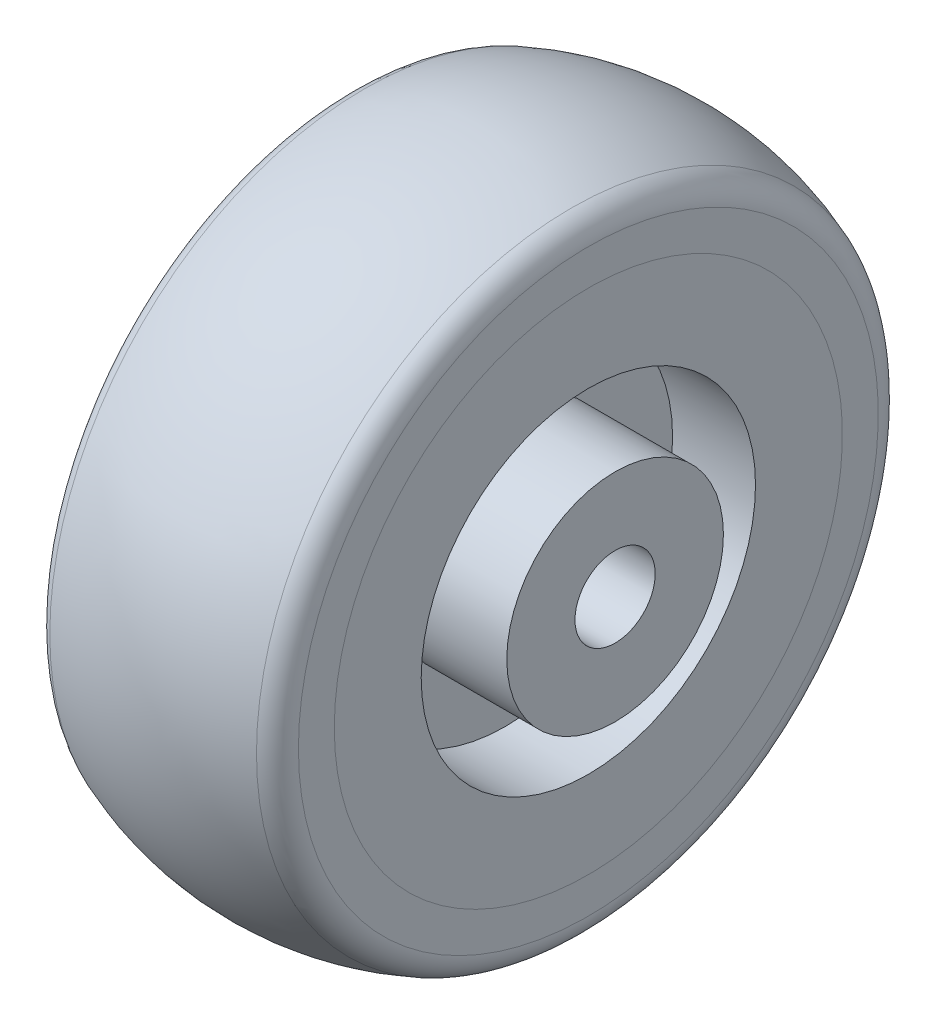
from build123d import *


with BuildPart() as part:
    # Esquisse2 → Révolution1 (revolve)
    with BuildSketch(Plane.XY):
        with BuildLine():
            Line((-11, 3), (11, 3))
            Line((11, 3), (11, 8.1))
            Line((11, 8.1), (2.8, 8.1))
            Line((2.8, 8.1), (2.8, 12.5))
            Line((2.8, 12.5), (9, 12.5))
            Line((9, 12.5), (9, 21.68216384))
            ThreePointArc((9, 21.68216384), (8.651445648, 22.81031599), (7.727272727, 23.545245798))
            ThreePointArc((7.727272727, 23.545245798), (0, 25), (-7.727272727, 23.545245798))
            ThreePointArc((-7.727272727, 23.545245798), (-8.651445648, 22.81031599), (-9, 21.68216384))
            Line((-9, 21.68216384), (-9, 12.5))
            Line((-9, 12.5), (-2.8, 12.5))
            Line((-2.8, 12.5), (-2.8, 8.1))
            Line((-2.8, 8.1), (-11, 8.1))
            Line((-11, 8.1), (-11, 3))
        make_face()
    revolve(axis=Axis((-11, 0, 0), (1, 0, 0)))


solid = part.part
